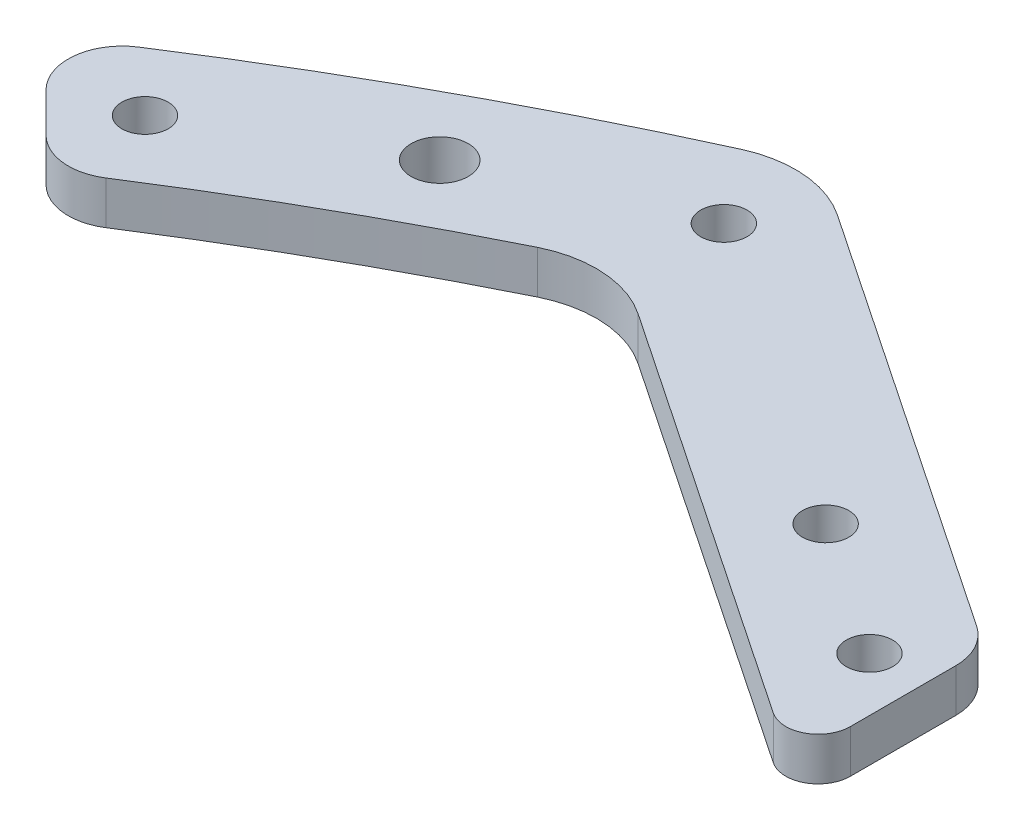
from build123d import *

# Parameters (mm, degrees)
SKETCH_1_R               = 275
SKETCH_1_R_2             = 255
EXTRUDE_1_DEPTH          = 10
EXTRUDE_2_DEPTH          = 10
SKETCH_8_R               = 2.65
SKETCH_8_R_2             = 2.15
CUT_EXTRUDE_1_DEPTH      = 21
SKETCH_9_OUTSIDE_W       = 707.614
SKETCH_9_OUTSIDE_H       = 707.614
CUT_EXTRUDE_2_DEPTH      = 21
SKETCH_10_W              = 190.987823936
SKETCH_10_H              = 12
CUT_EXTRUDE_3_DEPTH      = 519.420037555
CUT_EXTRUDE_3_DEPTH_BACK = 245.939436413
FILLET_1_R               = 3
FILLET_2_R               = 10
FILLET_3_R               = 5
SKETCH_11_W              = 751.740061758
SKETCH_11_H              = 25.075171634
CUT_EXTRUDE_4_DEPTH      = 519.420037555
CUT_EXTRUDE_4_DEPTH_BACK = 245.939436413


with BuildPart() as part:
    # 草图1 → 凸台-拉伸1 (new body)
    with BuildSketch(Plane(origin=(0, 0, 0), x_dir=(1, 0, 0), z_dir=(0, 1, 0))):
        Circle(SKETCH_1_R)
        Circle(SKETCH_1_R_2, mode=Mode.SUBTRACT)
    extrude(amount=EXTRUDE_1_DEPTH)

    # 草图11 → 切除-拉伸4 (cut, two sides)
    with BuildSketch(Plane(origin=(76.33674701, 0, -113.448714652), x_dir=(0.829665535, 0, 0.558260781), z_dir=(-0.558260781, 0, 0.829665535))) as cut_extrude_4_sk:
        with Locations((71.776229786, 3.462414183)):
            Rectangle(SKETCH_11_W, SKETCH_11_H)
    extrude(amount=CUT_EXTRUDE_4_DEPTH, mode=Mode.SUBTRACT)
    extrude(cut_extrude_4_sk.sketch, amount=-CUT_EXTRUDE_4_DEPTH_BACK, mode=Mode.SUBTRACT)


with BuildPart() as body_2:
    # 草图2 → 凸台-拉伸2 (new body)
    with BuildSketch(Plane(origin=(0, 10, 0), x_dir=(1, 0, 0), z_dir=(0, 1, 0))):
        with BuildLine():
            Line((-110.525139894, 257.262887824), (-25.423255477, 200))
            Line((-25.423255477, 200), (0, 200))
            Line((0, 200), (25.423255477, 200))
            Line((25.423255477, 200), (110.525139894, 257.262887824))
            ThreePointArc((110.525139894, 257.262887824), (197.989898732, 197.989898732), (257.262887824, 110.525139894))
            Line((257.262887824, 110.525139894), (200, 25.423255477))
            Line((200, 25.423255477), (200, 0))
            Line((200, 0), (200, -25.423255477))
            Line((200, -25.423255477), (257.262887824, -110.525139894))
            ThreePointArc((257.262887824, -110.525139894), (197.989898732, -197.989898732), (110.525139894, -257.262887824))
            Line((110.525139894, -257.262887824), (25.423255477, -200))
            Line((25.423255477, -200), (0, -200))
            Line((0, -200), (-25.423255477, -200))
            Line((-25.423255477, -200), (-110.525139894, -257.262887824))
            ThreePointArc((-110.525139894, -257.262887824), (-197.989898732, -197.989898732), (-257.262887824, -110.525139894))
            Line((-257.262887824, -110.525139894), (-200, -25.423255477))
            Line((-200, -25.423255477), (-200, 25.423255477))
            Line((-200, 25.423255477), (-257.262887824, 110.525139894))
            ThreePointArc((-257.262887824, 110.525139894), (-197.989898732, 197.989898732), (-110.525139894, 257.262887824))
        make_face()
        with BuildLine():
            Line((0, 185), (30, 185))
            Line((30, 185), (111.993839361, 240.171563565))
            ThreePointArc((111.993839361, 240.171563565), (187.383297014, 187.383297014), (240.171563565, 111.993839361))
            Line((240.171563565, 111.993839361), (185, 30))
            Line((185, 30), (185, 0))
            Line((185, 0), (185, -30))
            Line((185, -30), (240.171563565, -111.993839361))
            ThreePointArc((240.171563565, -111.993839361), (187.383297014, -187.383297014), (111.993839361, -240.171563565))
            Line((111.993839361, -240.171563565), (30, -185))
            Line((30, -185), (0, -185))
            Line((0, -185), (-30, -185))
            Line((-30, -185), (-111.993839361, -240.171563565))
            ThreePointArc((-111.993839361, -240.171563565), (-187.383297014, -187.383297014), (-240.171563565, -111.993839361))
            Line((-240.171563565, -111.993839361), (-185, -30))
            Line((-185, -30), (-185, 30))
            Line((-185, 30), (-240.171563565, 111.993839361))
            ThreePointArc((-240.171563565, 111.993839361), (-187.383297014, 187.383297014), (-111.993839361, 240.171563565))
            Line((-111.993839361, 240.171563565), (-30, 185))
            Line((-30, 185), (0, 185))
        make_face(mode=Mode.SUBTRACT)
    extrude(amount=EXTRUDE_2_DEPTH)

    # 草图8 → 切除-拉伸1 (cut, through all)
    with BuildSketch(Plane(origin=(0, 20, 0), x_dir=(1, 0, 0), z_dir=(0, 1, 0))):
        with Locations((-10, 192.5)):
            Circle(SKETCH_8_R)
        with Locations((10, 192.5)):
            Circle(SKETCH_8_R)
        with Locations((-10, -192.5)):
            Circle(SKETCH_8_R)
        with Locations((10, -192.5)):
            Circle(SKETCH_8_R)
        with Locations((192.5, 10)):
            Circle(SKETCH_8_R)
        with Locations((192.5, -10)):
            Circle(SKETCH_8_R)
        with Locations((-192.5, 10)):
            Circle(SKETCH_8_R)
        with Locations((-192.5, -10)):
            Circle(SKETCH_8_R)
        with Locations((-110.525139894, 248.223100485)):
            Circle(SKETCH_8_R_2)
        with Locations((-27.711627738, 192.5)):
            Circle(SKETCH_8_R_2)
        with Locations((-44.304938442, 203.665215623)):
            Circle(SKETCH_8_R_2)
        with Locations((-56.749921469, 212.03912734)):
            Circle(SKETCH_8_R_2)
        with Locations((-69.194904497, 220.413039057)):
            Circle(SKETCH_8_R_2)
        with Locations((-81.639887524, 228.786950774)):
            Circle(SKETCH_8_R_2)
        with Locations((-146.077022117, 230.028561882)):
            Circle(SKETCH_8_R_2)
        with Locations((-164.415519771, 217.299729706)):
            Circle(SKETCH_8_R_2)
        with Locations((-183.638937552, 201.316607082)):
            Circle(SKETCH_8_R_2)
        with Locations((-201.316607082, 183.638937552)):
            Circle(SKETCH_8_R_2)
        with Locations((-217.299729706, 164.415519771)):
            Circle(SKETCH_8_R_2)
        with Locations((-230.028561882, 146.077022117)):
            Circle(SKETCH_8_R_2)
        with Locations((-128.811575358, 240.123330241)):
            Circle(SKETCH_8_R)
        with Locations((-240.123330241, 128.811575358)):
            Circle(SKETCH_8_R)
        with Locations((-228.786950774, 81.639887524)):
            Circle(SKETCH_8_R_2)
        with Locations((-220.413039057, 69.194904497)):
            Circle(SKETCH_8_R_2)
        with Locations((-212.03912734, 56.749921469)):
            Circle(SKETCH_8_R_2)
        with Locations((-203.665215623, 44.304938442)):
            Circle(SKETCH_8_R_2)
        with Locations((-192.5, 27.711627738)):
            Circle(SKETCH_8_R_2)
        with Locations((-248.223100485, 110.525139894)):
            Circle(SKETCH_8_R_2)
        with Locations((192.5, 27.711627738)):
            Circle(SKETCH_8_R_2)
        with Locations((248.223100485, 110.525139894)):
            Circle(SKETCH_8_R_2)
        with Locations((203.665215623, 44.304938442)):
            Circle(SKETCH_8_R_2)
        with Locations((212.03912734, 56.749921469)):
            Circle(SKETCH_8_R_2)
        with Locations((220.413039057, 69.194904497)):
            Circle(SKETCH_8_R_2)
        with Locations((228.786950774, 81.639887524)):
            Circle(SKETCH_8_R_2)
        with Locations((240.123330241, 128.811575358)):
            Circle(SKETCH_8_R)
        with Locations((230.028561882, 146.077022117)):
            Circle(SKETCH_8_R_2)
        with Locations((128.811575358, 240.123330241)):
            Circle(SKETCH_8_R)
        with Locations((201.316607082, 183.638937552)):
            Circle(SKETCH_8_R_2)
        with Locations((183.638937552, 201.316607082)):
            Circle(SKETCH_8_R_2)
        with Locations((164.415519771, 217.299729706)):
            Circle(SKETCH_8_R_2)
        with Locations((146.077022117, 230.028561882)):
            Circle(SKETCH_8_R_2)
        with Locations((81.639887524, 228.786950774)):
            Circle(SKETCH_8_R_2)
        with Locations((69.194904497, 220.413039057)):
            Circle(SKETCH_8_R_2)
        with Locations((56.749921469, 212.03912734)):
            Circle(SKETCH_8_R_2)
        with Locations((44.304938442, 203.665215623)):
            Circle(SKETCH_8_R_2)
        with Locations((110.525139894, 248.223100485)):
            Circle(SKETCH_8_R_2)
        with Locations((27.711627738, 192.5)):
            Circle(SKETCH_8_R_2)
        with Locations((217.299729706, 164.415519771)):
            Circle(SKETCH_8_R_2)
    extrude(amount=-CUT_EXTRUDE_1_DEPTH, mode=Mode.SUBTRACT)

    # 草图9 outside → 切除-拉伸2 (cut, through all)
    with BuildSketch(Plane(origin=(0, 20, 0), x_dir=(1, 0, 0), z_dir=(0, 1, 0))):
        Rectangle(SKETCH_9_OUTSIDE_W, SKETCH_9_OUTSIDE_H)
        with BuildLine():
            Line((-157.049761777, 231.808913387), (-146.237600169, 220.996751779))
            ThreePointArc((-146.237600169, 220.996751779), (-129.47118383, 231.218971016), (-111.993839361, 240.171563565))
            Line((-111.993839361, 240.171563565), (-64.194904497, 208.008879225))
            Line((-64.194904497, 208.008879225), (-64.194904497, 226.088453902))
            Line((-64.194904497, 226.088453902), (-110.525139894, 257.262887824))
            ThreePointArc((-110.525139894, 257.262887824), (-134.391436501, 245.639861983), (-157.049761777, 231.808913387))
        make_face(mode=Mode.SUBTRACT)
    extrude(amount=-CUT_EXTRUDE_2_DEPTH, mode=Mode.SUBTRACT)

    # 草图10 → 切除-拉伸3 (cut, two sides)
    with BuildSketch(Plane(origin=(76.33674701, 0, -113.448714652), x_dir=(0.829665535, 0, 0.558260781), z_dir=(-0.558260781, 0, 0.829665535))) as cut_extrude_3_sk:
        with Locations((-226.995793353, 10)):
            Rectangle(SKETCH_10_W, SKETCH_10_H)
    extrude(amount=CUT_EXTRUDE_3_DEPTH, mode=Mode.SUBTRACT)
    extrude(cut_extrude_3_sk.sketch, amount=-CUT_EXTRUDE_3_DEPTH_BACK, mode=Mode.SUBTRACT)

    # 圆角1
    fillet_1_edges = [body_2.edges().sort_by_distance(p)[0] for p in [
        (-64.194904497, 18, -208.008879225),
    ]]
    fillet(fillet_1_edges, radius=FILLET_1_R)

    # 圆角2
    fillet_2_edges = [body_2.edges().sort_by_distance(p)[0] for p in [
        (-110.525139894, 18, -257.262887824),
        (-111.993839361, 18, -240.171563565),
    ]]
    fillet(fillet_2_edges, radius=FILLET_2_R)

    # 圆角3
    fillet_3_edges = [body_2.edges().sort_by_distance(p)[0] for p in [
        (-146.237600169, 18, -220.996751779),
        (-64.194904497, 18, -226.088453902),
        (-157.049761777, 18, -231.808913387),
    ]]
    fillet(fillet_3_edges, radius=FILLET_3_R)


solid = body_2.part
